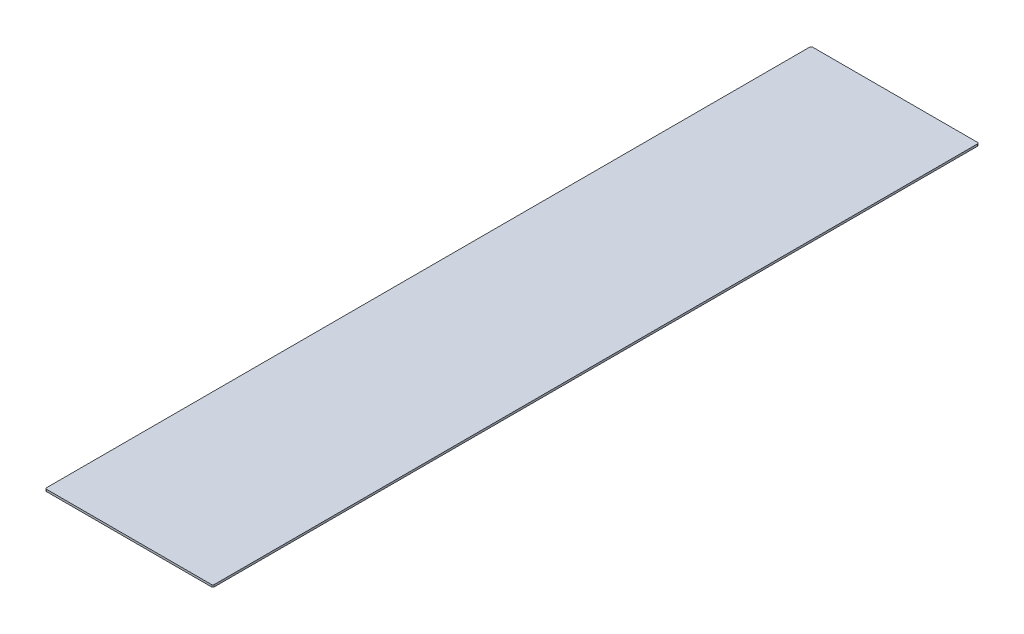
from build123d import *

# Parameters (mm, degrees)
BOSS_EXTRUDE1_DEPTH = 3


with BuildPart() as part:
    # Sketch2 → Boss-Extrude1 (new body)
    with BuildSketch(Plane(origin=(0, 0, 0), x_dir=(1, 0, 0), z_dir=(0, 1, 0))):
        with BuildLine():
            Line((-118.75, -551.5), (118.75, -551.5))
            ThreePointArc((118.75, -551.5), (120.164213562, -550.914213562), (120.75, -549.5))
            Line((120.75, -549.5), (120.75, 549.5))
            ThreePointArc((120.75, 549.5), (120.164213562, 550.914213562), (118.75, 551.5))
            Line((118.75, 551.5), (-118.75, 551.5))
            ThreePointArc((-118.75, 551.5), (-120.164213562, 550.914213562), (-120.75, 549.5))
            Line((-120.75, 549.5), (-120.75, -549.5))
            ThreePointArc((-120.75, -549.5), (-120.164213562, -550.914213562), (-118.75, -551.5))
        make_face()
    extrude(amount=BOSS_EXTRUDE1_DEPTH)


solid = part.part
